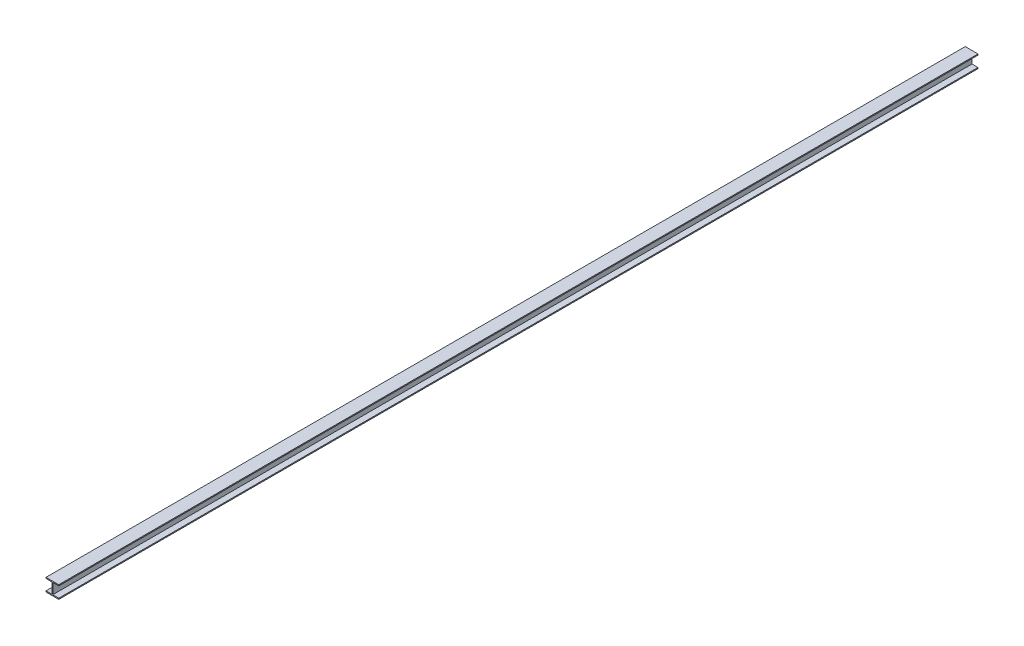
from build123d import *

# Parameters (mm, degrees)
RAIL_DEPTH = 4572


with BuildPart() as part:
    # Sketch1 → RAIL (new body, symmetric)
    with BuildSketch(Plane.XY):
        Polygon((-63.5, 116.5352), (63.5, 116.5352), (63.5, 106.0704), (3.9751, 106.0704), (3.9751, 0), (63.5, 0), (63.5, -10.4648), (-63.5, -10.4648), (-63.5, 0), (-3.9751, 0), (-3.9751, 106.0704), (-63.5, 106.0704), align=None)
    extrude(amount=RAIL_DEPTH, both=True)


solid = part.part
